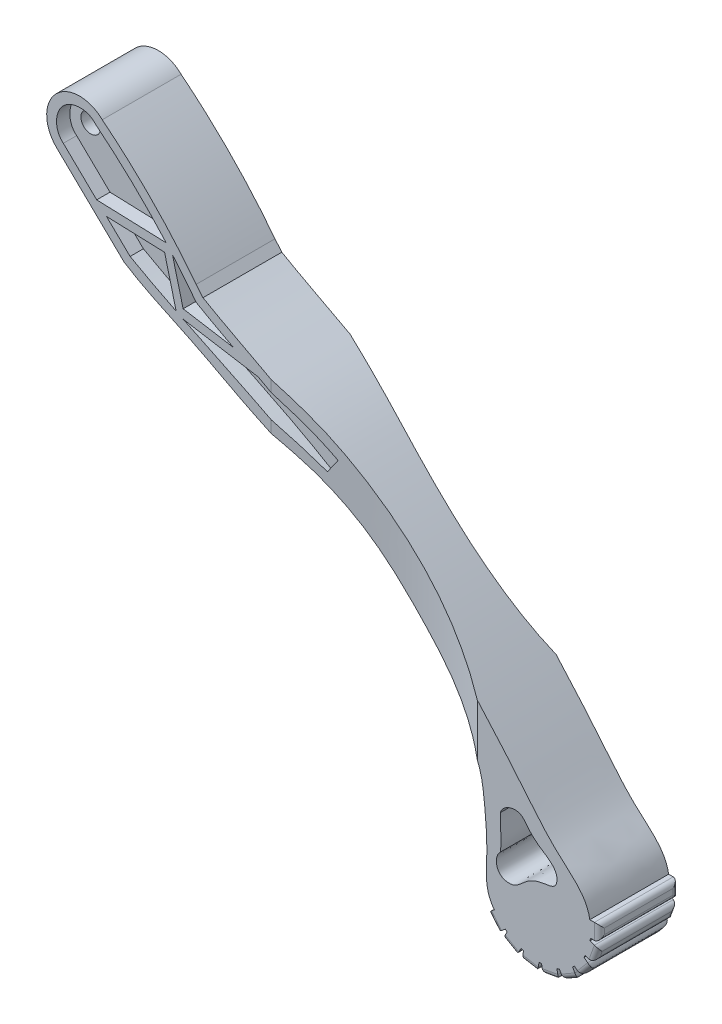
from build123d import *

# Parameters (mm, degrees)
BOSS_EXTRUDE2_DEPTH      = 20.32
BOSS_EXTRUDE2_DEPTH_BACK = 20.32
CUT_EXTRUDE5_DEPTH       = 6.858
SKETCH10_R               = 5.08
BOSS_EXTRUDE4_DEPTH      = 20.32
CUT_EXTRUDE9_DEPTH       = 621.03
CUT_EXTRUDE10_DEPTH      = 621.03
CUT_EXTRUDE10_DEPTH_BACK = 621.03
BOSS_EXTRUDE10_DEPTH     = 40.64
CIRPATTERN2_COUNT        = 8
CIRPATTERN2_ANGLE        = 140
FILLET2_R                = 2.54
SKETCH16_R               = 5.08
CUT_EXTRUDE11_DEPTH      = 26.162
CUT_EXTRUDE11_DEPTH_BACK = 28.448


with BuildPart() as part:
    # Sketch1 → Boss-Extrude2 (new body, two sides)
    with BuildSketch(Plane.XY) as boss_extrude2_sk:
        with BuildLine():
            Line((26.555892649, -34.549758293), (-8.228010955, -0.901839267))
            ThreePointArc((-8.228010955, -0.901839267), (-8.624726415, 22.99633901), (15.273451862, 23.39305447))
            add(Edge.make_bspline(
                [(63.679946658, -25.878446408), (42.486868882, 1.576776186), (15.273451862, 23.39305447)],
                knots=[0, 0, 0, 1, 1, 1], degree=2))
            add(Edge.make_bspline(
                [(63.679946658, -25.878446408), (67.186082893, -30.095486573)],
                knots=[0, 0, 1, 1], degree=1))
            add(Edge.make_bspline(
                [(67.186082893, -30.095486573), (85.892401916, -40.961318642), (114.134321186, -53.462366378), (171.479624661, -98.242882962), (212.655064019, -141.53909198), (249.754393979, -188.014279069), (265.145504204, -198.346410728), (266.641244673, -208.280000944)],
                knots=[0, 0, 0, 0, 0.240887908, 0.338156805, 0.805260578, 0.8970112, 1, 1, 1, 1], degree=3))
            ThreePointArc((266.641244673, -208.280000944), (250.961754751, -237.884960507), (218.530010546, -229.489604486))
            add(Edge.make_bspline(
                [(26.555892649, -34.549758293), (38.326960899, -42.025122412), (60.506971906, -51.110209239), (90.508165945, -68.118639305), (121.407205502, -81.307668984), (149.520641902, -102.706873182), (173.395338348, -128.586541847), (195.700730308, -147.030985212), (210.255951378, -165.321970691), (212.596295777, -185.160744409), (214.466252296, -205.702066298), (212.035743845, -222.847622099), (218.530010546, -229.489604486)],
                knots=[0, 0, 0, 0, 0.142543266, 0.24485293, 0.353362294, 0.485794747, 0.603192184, 0.713140253, 0.784773881, 0.83363507, 0.913762621, 1, 1, 1, 1], degree=3))
        make_face()
    extrude(amount=BOSS_EXTRUDE2_DEPTH)
    extrude(boss_extrude2_sk.sketch, amount=-BOSS_EXTRUDE2_DEPTH_BACK)

    # Sketch7 → Cut-Extrude5 (cut)
    with BuildSketch(Plane.XY.offset(20.32)):
        with BuildLine():
            Line((131.338729057, -73.393440536), (126.649608546, -80.400635899))
            add(Edge.make_bspline(
                [(126.649608546, -80.400635899), (122.701087468, -78.02995489), (114.690517721, -73.450023063), (98.476308959, -64.874568262), (77.932724243, -54.897005734), (57.477848803, -45.119584163), (41.409660311, -36.940638084), (33.529695389, -32.663136109), (29.624623424, -30.450402984)],
                knots=[0.042191373, 0.042191373, 0.042191373, 0.042191373, 0.161209022, 0.280226672, 0.518261971, 0.75629727, 0.87531492, 0.994332569, 0.994332569, 0.994332569, 0.994332569], degree=3))
            Line((29.624623424, -30.450402984), (-4.807753886, 2.857470012))
            add(Edge.make_bspline(
                [(-4.807753886, 2.857470012), (-4.835857807, 2.881509965), (-4.89679844, 2.93363877), (-4.980817386, 3.005505174), (-5.099012185, 3.109380587), (-5.347373437, 3.33724694), (-5.802820703, 3.797083427), (-6.618982402, 4.786886483), (-7.510122998, 6.376793201), (-8.164767501, 8.555318919), (-8.449759849, 11.710410092), (-7.81887862, 14.982069544), (-6.37638164, 17.809636486), (-4.987639001, 19.564872259), (-3.242630985, 20.994470949), (-1.128109678, 22.121311932), (1.212186689, 22.851108749), (3.640847992, 23.143679373), (6.008759642, 22.979730628), (7.823904183, 22.473452402), (9.141911162, 21.857610137), (9.907353188, 21.384897887), (10.484795324, 20.951448949), (10.830767532, 20.657096363), (11.100035685, 20.405281362), (11.262275115, 20.244065374), (11.395611927, 20.104897412), (11.50676319, 19.98545279), (11.677662155, 19.796251239), (11.772116757, 19.69223088)],
                knots=[-0.002762942, -0.002762942, -0.002762942, -0.002762942, -0.000790947, 0.001181048, 0.005125037, 0.013013015, 0.028788972, 0.060340885, 0.123444711, 0.186548538, 0.249652364, 0.375860017, 0.438963844, 0.50206767, 0.565171497, 0.628275323, 0.691379149, 0.754482976, 0.817586802, 0.880690629, 0.912242542, 0.943794455, 0.959570412, 0.975346368, 0.983234347, 0.991122325, 0.995066314, 0.999010303, 1.006898282, 1.006898282, 1.006898282, 1.006898282], degree=3))
            add(Edge.make_bspline(
                [(11.772116757, 19.69223088), (30.09454163, 4.855130422), (50.534242369, -17.573454044), (57.260432736, -25.665001317), (60.537534077, -29.794166945), (62.68993604, -32.570822681), (63.766152401, -33.988423008)],
                knots=[-0.0136429, -0.0136429, -0.0136429, 0.623091546, 0.81411188, 0.909622047, 0.957377131, 1.005132214, 1.005132214, 1.005132214], degree=2))
            add(Edge.make_bspline(
                [(63.766152401, -33.988423008), (64.483858637, -34.401526358), (65.915564512, -35.225883291), (68.82099612, -36.867878247), (73.908737789, -39.682632223), (84.142299995, -45.155035386), (98.725763296, -52.756660285), (115.686107805, -62.32737106), (126.272079704, -69.479562552), (131.338729057, -73.393440536)],
                knots=[0.057213046, 0.057213046, 0.057213046, 0.057213046, 0.087062226, 0.116911406, 0.176609767, 0.296006489, 0.534799931, 0.773593374, 1.012386817, 1.012386817, 1.012386817, 1.012386817], degree=3))
        make_face()
    cut_extrude5 = extrude(amount=-CUT_EXTRUDE5_DEPTH, mode=Mode.SUBTRACT)

    # Mirror1: Cut-Extrude5 across plane
    add(cut_extrude5.mirror(Plane.XY), mode=Mode.SUBTRACT)

    # Sketch10 → Boss-Extrude4 (add)
    with BuildSketch(Plane.XY):
        with Locations((2.492971561, 12.33414506)):
            Circle(SKETCH10_R)
        Polygon((12.408434769, -13.796466486), (50.535063514, -15.141475661), (56.959579408, -40.151562468), (82.889972419, -44.463419929), (83.63619466, -43.1575672), (96.149282096, -50.308101054), (95.632415888, -51.21259185), (53.697424409, -44.239396118), (47.397105811, -19.712798682), (17.431717385, -18.655697026), (16.489795124, -19.629419446), (11.461038002, -14.775848236), align=None)
    extrude(amount=BOSS_EXTRUDE4_DEPTH)

    # Mirror3: part across plane


with BuildPart() as part_1:
    add(part.part)
    add(part.part.mirror(Plane.XY))

    # Sketch11 → Cut-Extrude9 (cut)
    with BuildSketch(Plane(origin=(0, 0, 0), x_dir=(1, 0, 0), z_dir=(0, 1, 0))):
        with BuildLine():
            add(Edge.make_bspline(
                [(102.379637842, -20.32), (135.913234179, -13.619345361), (176.226510317, -4.5731221), (208.625486306, -20.32)],
                knots=[0, 0, 0, 0, 1, 1, 1, 1], degree=3))
            Line((102.379637842, -20.32), (208.625486306, -20.32))
        make_face()
        with BuildLine():
            Line((208.625486306, 20.32), (102.379637842, 20.32))
            add(Edge.make_bspline(
                [(102.379637842, 20.32), (135.913234179, 13.619345361), (176.226510317, 4.5731221), (208.625486306, 20.32)],
                knots=[0, 0, 0, 0, 1, 1, 1, 1], degree=3))
        make_face()
    extrude(amount=-CUT_EXTRUDE9_DEPTH, mode=Mode.SUBTRACT)

    # Sketch12 → Cut-Extrude10 (cut, two sides)
    with BuildSketch(Plane.XY) as cut_extrude10_sk:
        with BuildLine():
            add(Edge.make_bspline(
                [(220.513233367, -183.301780216), (221.543139855, -179.43662909), (230.163436553, -176.010910731), (235.049008659, -183.627699677), (239.612943498, -187.856246896), (245.331761451, -191.290893035), (250.333960193, -195.772993809), (249.262222459, -203.049086742), (242.287449109, -203.64472997), (236.424848876, -205.269254627), (231.695144815, -209.125352054), (227.474336764, -213.189825195), (217.770572027, -212.172488029), (217.780191508, -203.313134508), (220.513233367, -200.953951324)],
                knots=[0, 0, 0, 0, 0.140788575, 0.215539904, 0.293168664, 0.361812078, 0.454084372, 0.509749601, 0.573953648, 0.668559338, 0.729437766, 0.786274804, 0.872193101, 1, 1, 1, 1], degree=3))
            add(Edge.make_bspline(
                [(220.513233367, -200.953951324), (221.388369863, -195.071262615), (220.211349215, -189.194551573), (220.513233367, -183.301780216)],
                knots=[0, 0, 0, 0, 1, 1, 1, 1], degree=3))
        make_face()
    extrude(amount=CUT_EXTRUDE10_DEPTH, mode=Mode.SUBTRACT)
    extrude(cut_extrude10_sk.sketch, amount=-CUT_EXTRUDE10_DEPTH_BACK, mode=Mode.SUBTRACT)

    # Sketch13 → Boss-Extrude10 (add)
    with BuildSketch(Plane.XY.offset(20.32)):
        Polygon((265.844780294, -208.088009836), (271.528548497, -208.088009836), (271.528548497, -216.172403976), (266.051440648, -216.172403976), (262.556014734, -212.365230883), align=None)
    boss_extrude10 = extrude(amount=-BOSS_EXTRUDE10_DEPTH)

    # CirPattern2: Boss-Extrude10 ×8 about axis
    cirpattern2_axis = Axis((240.060456132, -213.156778807, 0), (0, 0, -1))
    for i in range(1, CIRPATTERN2_COUNT):
        add(boss_extrude10.rotate(cirpattern2_axis, i * CIRPATTERN2_ANGLE / (CIRPATTERN2_COUNT - 1)))

    # Fillet2
    fillet2_edges = [part_1.edges().sort_by_distance(p)[0] for p in [
        (271.528548497, -212.130206906, -20.32),
        (271.528548497, -216.172403976, 0),
        (271.528548497, -208.088009836, 0),
        (271.528548497, -212.130206906, 20.32),
        (269.981898586, -222.954838228, -20.32),
        (268.599385765, -226.753260986, 0),
        (271.364411407, -219.156415469, 0),
        (269.981898586, -222.954838228, 20.32),
        (264.826281122, -232.597678979, -20.32),
        (262.228006929, -235.694181583, 0),
        (267.424555315, -229.501176376, 0),
        (264.826281122, -232.597678979, 20.32),
        (256.683539659, -239.895660253, -20.32),
        (253.182894309, -241.916758788, 0),
        (260.184185009, -237.874561718, 0),
        (256.683539659, -239.895660253, 20.32),
        (246.535808992, -243.968537801, -20.32),
        (242.555021978, -244.670457956, 0),
        (250.516596007, -243.266617645, 0),
        (246.535808992, -243.968537801, 20.32),
        (235.607055205, -244.32506248, -20.32),
        (231.626268191, -243.623142325, 0),
        (239.587842219, -245.026982635, 0),
        (235.607055205, -244.32506248, 20.32),
        (225.215447294, -240.922232154, -20.32),
        (221.714801944, -238.901133619, 0),
        (228.716092644, -242.943330689, 0),
        (225.215447294, -240.922232154, 20.32),
        (216.614366538, -234.170478379, -20.32),
        (214.016092345, -231.073975776, 0),
        (219.212640731, -237.266980983, 0),
        (216.614366538, -234.170478379, 20.32),
    ]]
    fillet(fillet2_edges, radius=FILLET2_R)

    # Sketch16 → Cut-Extrude11 (cut, two sides)
    with BuildSketch(Plane.XY) as cut_extrude11_sk:
        with Locations((2.492971561, 12.33414506)):
            Circle(SKETCH16_R)
    extrude(amount=CUT_EXTRUDE11_DEPTH, mode=Mode.SUBTRACT)
    extrude(cut_extrude11_sk.sketch, amount=-CUT_EXTRUDE11_DEPTH_BACK, mode=Mode.SUBTRACT)


solid = part_1.part
